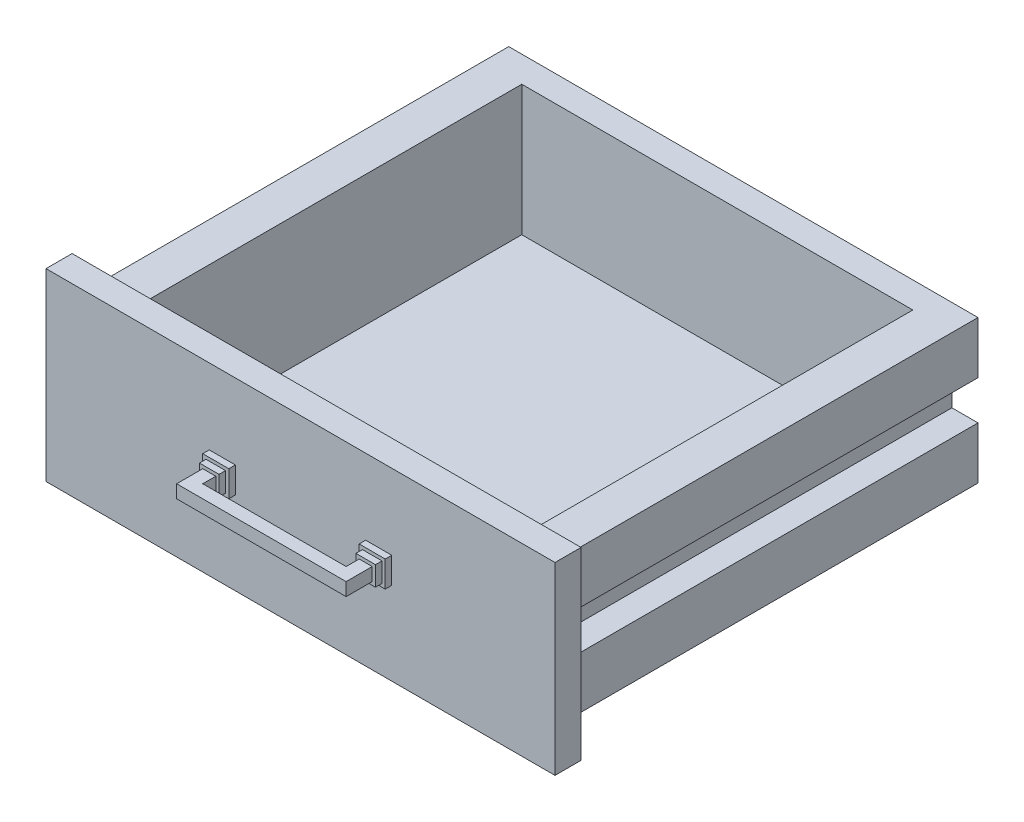
from build123d import *

# Parameters (mm, degrees)
BOSS_EXTRUDE1_DEPTH = 320
SKETCH2_W           = 390.491901408
SKETCH2_H           = 141.475704226
BOSS_EXTRUDE2_DEPTH = 20
SKETCH4_W           = 300
SKETCH4_H           = 300
CUT_EXTRUDE1_DEPTH  = 100
SKETCH5_W           = 20
SKETCH5_H           = 20
BOSS_EXTRUDE3_DEPTH = 5
SKETCH6_W           = 15
SKETCH6_H           = 15
BOSS_EXTRUDE4_DEPTH = 5
SKETCH7_W           = 10
SKETCH7_H           = 10
BOSS_EXTRUDE6_DEPTH = 20
BOSS_EXTRUDE7_REACH = 252.246
SKETCH8_W           = 10
SKETCH8_H           = 10


with BuildPart() as part:
    # Sketch1 → Boss-Extrude1 (new body)
    with BuildSketch(Plane.XY):
        Polygon((-180.245950704, 55.737852113), (179.754049296, 55.737852113), (179.754049296, 15.737852113), (159.754049296, 15.737852113), (159.754049296, -14.262147887), (179.754049296, -14.262147887), (179.754049296, -54.262147887), (-180.245950704, -54.262147887), (-180.245950704, -14.262147887), (-160.245950704, -14.262147887), (-160.245950704, 15.737852113), (-180.245950704, 15.737852113), align=None)
    extrude(amount=-BOSS_EXTRUDE1_DEPTH)

    # Sketch2 → Boss-Extrude2 (add)
    with BuildSketch(Plane.XY):
        Rectangle(SKETCH2_W, SKETCH2_H)
    extrude(amount=BOSS_EXTRUDE2_DEPTH)

    # Sketch4 → Cut-Extrude1 (cut)
    with BuildSketch(Plane(origin=(0, 55.737852113, 0), x_dir=(1, 0, 0), z_dir=(0, 1, 0))):
        with Locations((-0.245950704, 150)):
            Rectangle(SKETCH4_W, SKETCH4_H)
    extrude(amount=-CUT_EXTRUDE1_DEPTH, mode=Mode.SUBTRACT)

    # Sketch5 → Boss-Extrude3 (add)
    with BuildSketch(Plane.XY.offset(20)):
        with Locations((-60, 2.912454094)):
            Rectangle(SKETCH5_W, SKETCH5_H)
        with Locations((60, 2.912454094)):
            Rectangle(SKETCH5_W, SKETCH5_H)
    extrude(amount=BOSS_EXTRUDE3_DEPTH)

    # Sketch6 → Boss-Extrude4 (add)
    with BuildSketch(Plane.XY.offset(25)):
        with Locations((-60, 2.912454094)):
            Rectangle(SKETCH6_W, SKETCH6_H)
        with Locations((60, 2.912454094)):
            Rectangle(SKETCH6_W, SKETCH6_H)
    extrude(amount=BOSS_EXTRUDE4_DEPTH)

    # Sketch7 → Boss-Extrude6 (add)
    with BuildSketch(Plane.XY.offset(30)):
        with Locations((-60, 2.912454094)):
            Rectangle(SKETCH7_W, SKETCH7_H)
        with Locations((60, 2.912454094)):
            Rectangle(SKETCH7_W, SKETCH7_H)
    extrude(amount=BOSS_EXTRUDE6_DEPTH)

    # Sketch8 → Boss-Extrude7 (add, up to next)
    with BuildSketch(Plane.ZY.offset(-55), mode=Mode.PRIVATE) as boss_extrude7_sk1:
        with Locations((45, 2.912454094)):
            Rectangle(SKETCH8_W, SKETCH8_H)
    boss_extrude7_tool1 = extrude(boss_extrude7_sk1.sketch, amount=BOSS_EXTRUDE7_REACH, mode=Mode.PRIVATE) - part.part
    add(boss_extrude7_tool1.solids().sort_by_distance((55, 2.912454, 45))[0])


solid = part.part
